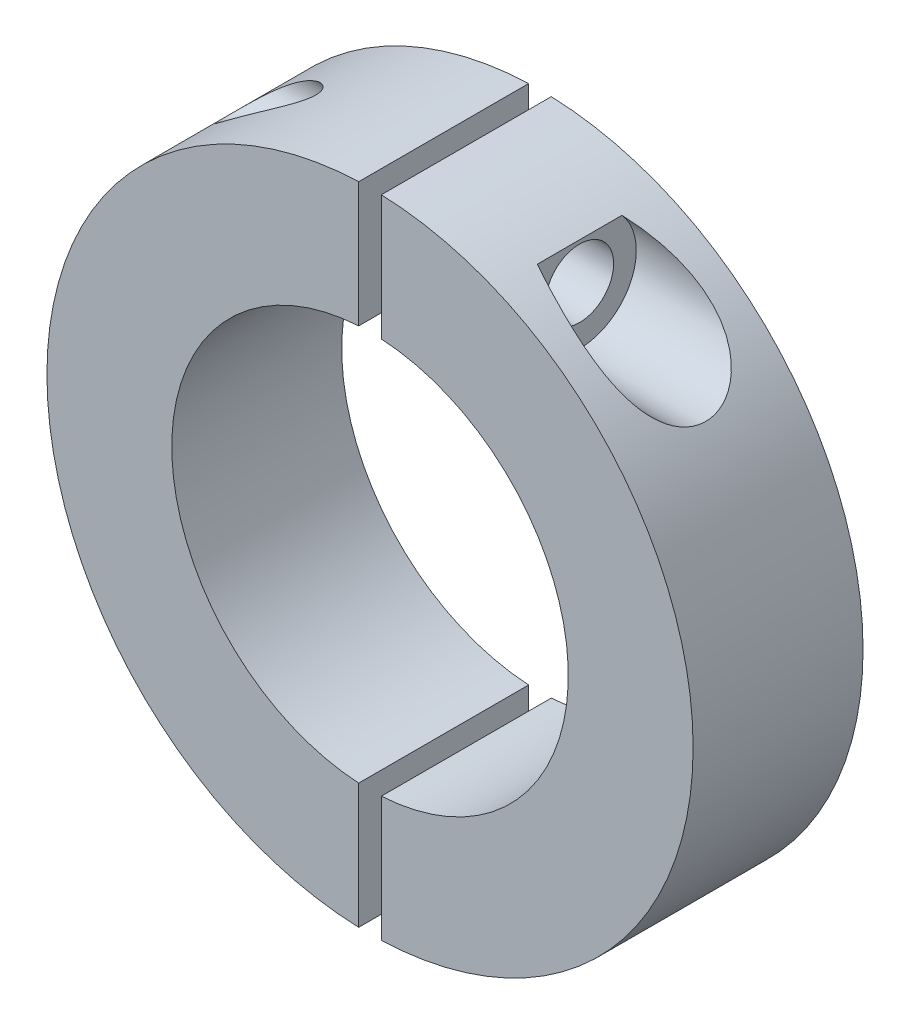
from build123d import *

# Parameters (mm, degrees)
EXTRUDE_1_DEPTH          = 15
EXTRUDE_1_2_DEPTH        = 15
SKETCH_2_R               = 2.75
CUT_EXTRUDE_1_DEPTH      = 29.517538463
SKETCH_3_R               = 5
CUT_EXTRUDE_2_DEPTH      = 18.517538563
SKETCH_4_R               = 3
CUT_EXTRUDE_3_DEPTH      = 10
PATTERN_CIRCULAR_1_COUNT = 2


with BuildPart() as part:
    # Эскиз1 → Бобышка-Вытянуть1 (new body)
    with BuildSketch(Plane.XY):
        with BuildLine():
            ThreePointArc((-1, 28.5), (-20.515451963, 19.808236438), (-28.517538463, 0))
            ThreePointArc((-28.517538463, 0), (-20.515451963, -19.808236438), (-1, -28.5))
            Line((-1, -28.5), (-1, -17.47140521))
            ThreePointArc((-1, -17.47140521), (-12.72301065, -12.015614841), (-17.5, 0))
            ThreePointArc((-17.5, 0), (-12.72301065, 12.015614841), (-1, 17.47140521))
            Line((-1, 17.47140521), (-1, 28.5))
        make_face()
    extrude(amount=-EXTRUDE_1_DEPTH)


with BuildPart() as body_2:
    # Эскиз1 → Extrude 1 2 (new body)
    with BuildSketch(Plane.XY):
        with BuildLine():
            Line((1, -17.47140521), (1, -28.5))
            ThreePointArc((1, -28.5), (20.515451963, -19.808236438), (28.517538463, 0))
            ThreePointArc((28.517538463, 0), (20.515451963, 19.808236438), (1, 28.5))
            Line((1, 28.5), (1, 17.47140521))
            ThreePointArc((1, 17.47140521), (12.72301065, 12.015614841), (17.5, 0))
            ThreePointArc((17.5, 0), (12.72301065, -12.015614841), (1, -17.47140521))
        make_face()
    extrude(amount=-EXTRUDE_1_2_DEPTH)


with BuildPart() as cut_extrude_1_tool:
    # Эскиз2 → Вырез-Вытянуть1 (new body, symmetric)
    with BuildSketch(Plane(origin=(0, 0, 0), x_dir=(0, 0, -1), z_dir=(1, 0, 0))):
        with Locations((7.5, 22.985702605)):
            Circle(SKETCH_2_R)
    cut_extrude_1 = extrude(amount=CUT_EXTRUDE_1_DEPTH, both=True)


with BuildPart() as part_1:
    add(part.part)

    # Вырез-Вытянуть1: cut by cut_extrude_1_tool
    add(cut_extrude_1_tool.part, mode=Mode.SUBTRACT)


with BuildPart() as body_2_1:
    add(body_2.part)

    # Вырез-Вытянуть1: cut by cut_extrude_1_tool
    add(cut_extrude_1_tool.part, mode=Mode.SUBTRACT)

    # Эскиз3 → Вырез-Вытянуть2 (cut, through all)
    with BuildSketch(Plane(origin=(11, 0, 0), x_dir=(0, 0, -1), z_dir=(1, 0, 0))):
        with Locations((7.5, 22.985702605)):
            Circle(SKETCH_3_R)
    cut_extrude_2 = extrude(amount=CUT_EXTRUDE_2_DEPTH, mode=Mode.SUBTRACT)

    # Эскиз4 → Вырез-Вытянуть3 (cut)
    with BuildSketch(Plane(origin=(11, 0, 0), x_dir=(0, 0, -1), z_dir=(1, 0, 0))):
        with Locations((7.5, 22.985702605)):
            Circle(SKETCH_4_R)
    cut_extrude_3 = extrude(amount=-CUT_EXTRUDE_3_DEPTH, mode=Mode.SUBTRACT)


with BuildPart() as pattern_circular_1_tool:
    # Круговой массив1: Вырез-Вытянуть1, Вырез-Вытянуть2, Вырез-Вытянуть3 ×2 about axis
    pattern_circular_1_axis = Axis((0, 0, -80.9), (0, 0, 1))
    for i in range(1, PATTERN_CIRCULAR_1_COUNT):
        add(cut_extrude_1.rotate(pattern_circular_1_axis, i * 360 / PATTERN_CIRCULAR_1_COUNT))
        add(cut_extrude_2.rotate(pattern_circular_1_axis, i * 360 / PATTERN_CIRCULAR_1_COUNT))
        add(cut_extrude_3.rotate(pattern_circular_1_axis, i * 360 / PATTERN_CIRCULAR_1_COUNT))


with BuildPart() as part_2:
    add(part_1.part)

    # Круговой массив1: cut by pattern_circular_1_tool
    add(pattern_circular_1_tool.part, mode=Mode.SUBTRACT)


with BuildPart() as body_2_2:
    add(body_2_1.part)

    # Круговой массив1: cut by pattern_circular_1_tool
    add(pattern_circular_1_tool.part, mode=Mode.SUBTRACT)


solid = Compound([part_2.part, body_2_2.part])
